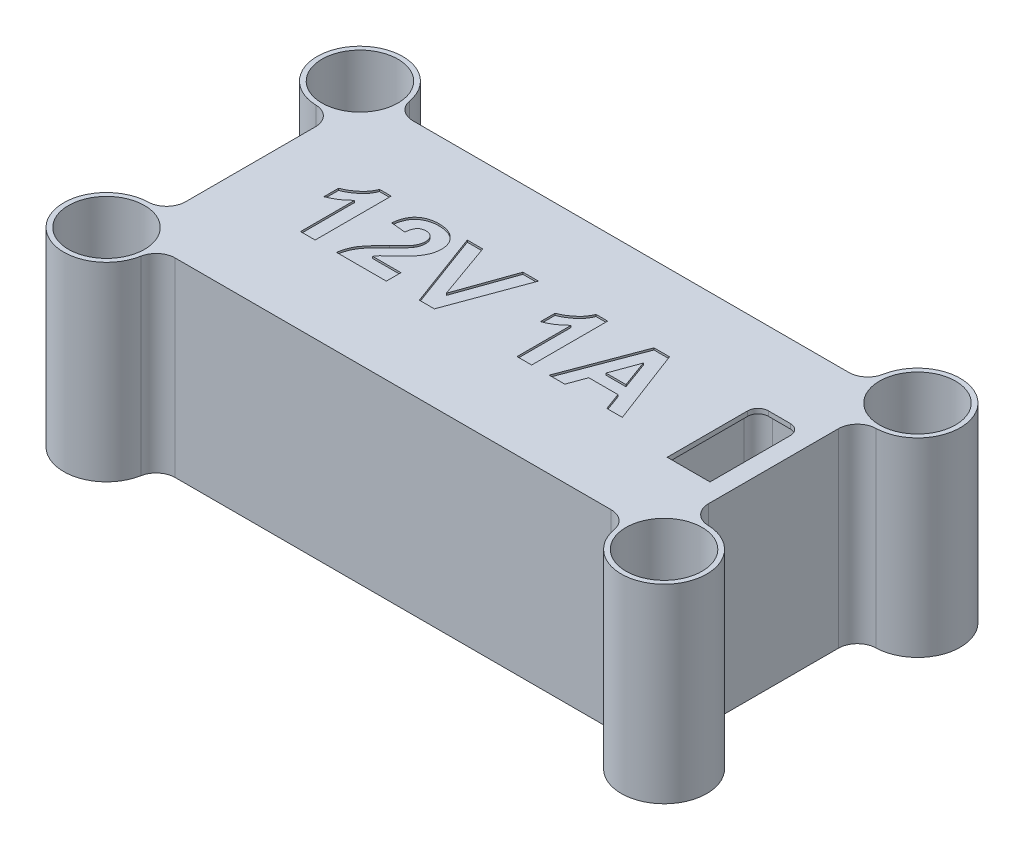
from build123d import *

# Parameters (mm, degrees)
SKETCH1_R           = 2
BOSS_EXTRUDE1_DEPTH = 20
SKETCH2_R           = 4
CUT_EXTRUDE1_DEPTH  = 18.5
CUT_EXTRUDE2_REACH  = 22.5
CUT_EXTRUDE2_START  = -0.5
SKETCH5_W           = 6.8
SKETCH5_H           = 4.325
CUT_EXTRUDE4_DEPTH  = 18.5
CUT_EXTRUDE6_REACH  = 2.5
SKETCH8_W           = 6.8
SKETCH8_H           = 13.35
CUT_EXTRUDE7_DEPTH  = 8.8
FILLET1_R           = 2
CUT_EXTRUDE8_DEPTH  = 0.2
SKETCH10_W          = 1.8
SKETCH10_H          = 1.5
BOSS_EXTRUDE2_DEPTH = 1
CHAMFER1_SIZE       = 0.5


with BuildPart() as part:
    # Sketch1 → Boss-Extrude1 (new body)
    with BuildSketch(Plane(origin=(0, 0, 0), x_dir=(1, 0, 0), z_dir=(0, 1, 0))):
        with BuildLine():
            Line((-24.820732955, -12.5), (24.820732955, -12.5))
            Line((24.820732955, -12.5), (24.820732955, -13.327605889))
            ThreePointArc((24.820732955, -13.327605889), (32.50271347, -16.509586404), (29.320732955, -8.827605889))
            Line((29.320732955, -8.827605889), (27.5, -8.827605889))
            Line((27.5, -8.827605889), (27.5, 8.827605889))
            Line((27.5, 8.827605889), (29.320732955, 8.827605889))
            ThreePointArc((29.320732955, 8.827605889), (32.50271347, 16.509586404), (24.820732955, 13.327605889))
            Line((24.820732955, 13.327605889), (24.820732955, 12.5))
            Line((24.820732955, 12.5), (-24.820732955, 12.5))
            Line((-24.820732955, 12.5), (-24.820732955, 13.327605889))
            ThreePointArc((-24.820732955, 13.327605889), (-32.50271347, 16.509586404), (-29.320732955, 8.827605889))
            Line((-29.320732955, 8.827605889), (-27.5, 8.827605889))
            Line((-27.5, 8.827605889), (-27.5, -8.827605889))
            Line((-27.5, -8.827605889), (-29.320732955, -8.827605889))
            ThreePointArc((-29.320732955, -8.827605889), (-32.50271347, -16.509586404), (-24.820732955, -13.327605889))
            Line((-24.820732955, -13.327605889), (-24.820732955, -12.5))
        make_face()
        with Locations((-29.320732955, -13.327605889)):
            Circle(SKETCH1_R, mode=Mode.SUBTRACT)
        with Locations((29.320732955, -13.327605889)):
            Circle(SKETCH1_R, mode=Mode.SUBTRACT)
        with Locations((-29.320732955, 13.327605889)):
            Circle(SKETCH1_R, mode=Mode.SUBTRACT)
        with Locations((29.320732955, 13.327605889)):
            Circle(SKETCH1_R, mode=Mode.SUBTRACT)
    extrude(amount=BOSS_EXTRUDE1_DEPTH)

    # Sketch2 → Cut-Extrude1 (cut)
    with BuildSketch(Plane(origin=(0, 20, 0), x_dir=(1, 0, 0), z_dir=(0, 1, 0))):
        with Locations((-29.320732955, 13.327605889)):
            Circle(SKETCH2_R)
        with Locations((29.320732955, 13.327605889)):
            Circle(SKETCH2_R)
        with Locations((29.320732955, -13.327605889)):
            Circle(SKETCH2_R)
        with Locations((-29.320732955, -13.327605889)):
            Circle(SKETCH2_R)
    extrude(amount=-CUT_EXTRUDE1_DEPTH, mode=Mode.SUBTRACT)

    # Sketch3 → Cut-Extrude2 (cut, up to next)
    with BuildSketch(Plane(origin=(0, 20, 0), x_dir=(1, 0, 0), z_dir=(0, 1, 0)).offset(CUT_EXTRUDE2_START), mode=Mode.PRIVATE) as cut_extrude2_sk1:
        with BuildLine():
            Line((22.2, 5.175), (24.5, 5.175))
            ThreePointArc((24.5, 5.175), (25.560660172, 4.735660172), (26, 3.675))
            Line((26, 3.675), (26, -5.175))
            Line((26, -5.175), (20.7, -5.175))
            Line((20.7, -5.175), (20.7, 3.675))
            ThreePointArc((20.7, 3.675), (21.139339828, 4.735660172), (22.2, 5.175))
        make_face()
    cut_extrude2_tool1 = extrude(cut_extrude2_sk1.sketch, amount=-CUT_EXTRUDE2_REACH, mode=Mode.PRIVATE) & part.part
    add(cut_extrude2_tool1.solids().sort_by_distance((23.35, 19.5, 0.086733))[0], mode=Mode.SUBTRACT)

    # Sketch5 → Cut-Extrude4 (cut)
    with BuildSketch(Plane.XZ):
        Polygon((-26, -11), (19.2, -11), (19.2, -6.675), (19.2, 6.675), (19.2, 11), (-26, 11), align=None)
        with Locations((22.6, 8.8375)):
            Rectangle(SKETCH5_W, SKETCH5_H)
        with Locations((22.6, -8.8375)):
            Rectangle(SKETCH5_W, SKETCH5_H)
    extrude(amount=-CUT_EXTRUDE4_DEPTH, mode=Mode.SUBTRACT)

    # Sketch7 → Cut-Extrude6 (cut, up to next)
    with BuildSketch(Plane.XZ.offset(-19.5), mode=Mode.PRIVATE) as cut_extrude6_sk1:
        with BuildLine():
            Line((25.6, -3.675), (25.6, 4.775))
            Line((25.6, 4.775), (21.1, 4.775))
            Line((21.1, 4.775), (21.1, -3.675))
            ThreePointArc((21.1, -3.675), (21.422182541, -4.452817459), (22.2, -4.775))
            Line((22.2, -4.775), (24.5, -4.775))
            ThreePointArc((24.5, -4.775), (25.277817459, -4.452817459), (25.6, -3.675))
        make_face()
    cut_extrude6_tool1 = extrude(cut_extrude6_sk1.sketch, amount=-CUT_EXTRUDE6_REACH, mode=Mode.PRIVATE) & part.part
    add(cut_extrude6_tool1.solids().sort_by_distance((23.35, 19.5, 0.055404))[0], mode=Mode.SUBTRACT)

    # Sketch8 → Cut-Extrude7 (cut)
    with BuildSketch(Plane.XZ):
        with Locations((22.6, 0)):
            Rectangle(SKETCH8_W, SKETCH8_H)
    extrude(amount=-CUT_EXTRUDE7_DEPTH, mode=Mode.SUBTRACT)

    # Fillet1
    fillet1_edges = [part.edges().sort_by_distance(p)[0] for p in [
        (-24.820732955, 10, 12.5),
        (27.5, 10, -8.827605889),
        (27.5, 10, 8.827605889),
        (-24.820732955, 10, -12.5),
        (24.820732955, 10, -12.5),
        (-27.5, 10, 8.827605889),
        (24.820732955, 10, 12.5),
        (-27.5, 10, -8.827605889),
    ]]
    fillet(fillet1_edges, radius=FILLET1_R)

    # Sketch9 → Cut-Extrude8 (cut)
    with BuildSketch(Plane(origin=(0, 20, 0), x_dir=(1, 0, 0), z_dir=(0, 1, 0))):
        with BuildLine():
            Line((-17.2, -3.503303036), (-18.738461538, -3.503303036))
            Line((-18.738461538, -3.503303036), (-18.738461538, 2.192209784))
            add(Edge.make_bspline(
                [(-18.738461538, 2.192209784), (-18.80819288, 2.121419465), (-18.946709583, 1.980799172), (-19.167942577, 1.784652614), (-19.397616155, 1.602184599), (-19.638003147, 1.43512824), (-19.88596108, 1.281103277), (-20.144023944, 1.141325029), (-20.410321211, 1.013859466), (-20.594796858, 0.942626015), (-20.687179487, 0.906953374)],
                knots=[0, 0, 0, 0, 0.00029803, 0.000592016, 0.000886347, 0.001177542, 0.001469724, 0.001761589, 0.002057651, 0.002354645, 0.002354645, 0.002354645, 0.002354645], degree=3))
            Line((-20.687179487, 0.906953374), (-20.687179487, 2.445414912))
            add(Edge.make_bspline(
                [(-20.687179487, 2.445414912), (-20.5847225, 2.483831886), (-20.370287998, 2.564235622), (-20.053854784, 2.735258446), (-19.723569975, 2.947001956), (-19.446111881, 3.154673304), (-19.22582156, 3.339309728), (-19.071855374, 3.487728442), (-18.929196849, 3.639716903), (-18.803208237, 3.800180743), (-18.690582276, 3.965875737), (-18.590790764, 4.136531192), (-18.502951295, 4.3126862), (-18.456967947, 4.435356639), (-18.433974359, 4.496696964)],
                knots=[0, 0, 0, 0, 0.000327943, 0.000686359, 0.001076233, 0.001504439, 0.001725023, 0.00193811, 0.002145634, 0.002349865, 0.002549441, 0.002746237, 0.002942614, 0.003139025, 0.003139025, 0.003139025, 0.003139025], degree=3))
            Line((-18.433974359, 4.496696964), (-17.2, 4.496696964))
            Line((-17.2, 4.496696964), (-17.2, -3.503303036))
        make_face()
        with BuildLine():
            Line((-9.712820513, -1.964841498), (-9.712820513, -3.503303036))
            Line((-9.712820513, -3.503303036), (-14.943589744, -3.503303036))
            add(Edge.make_bspline(
                [(-14.943589744, -3.503303036), (-14.925879571, -3.371819176), (-14.890469156, -3.108925181), (-14.780992812, -2.724903224), (-14.634879393, -2.350163406), (-14.47630103, -2.045216154), (-14.318577283, -1.79974411), (-14.175474519, -1.598602421), (-14.004758175, -1.384596297), (-13.808905531, -1.155998115), (-13.588998948, -0.912093283), (-13.343397782, -0.653788587), (-13.070930478, -0.382320603), (-12.879244876, -0.197980484), (-12.780128205, -0.102662011)],
                knots=[0, 0, 0, 0, 0.000397572, 0.00079492, 0.001194293, 0.001602869, 0.001823371, 0.00206928, 0.002343089, 0.002644324, 0.002972255, 0.00332819, 0.003713472, 0.004126007, 0.004126007, 0.004126007, 0.004126007], degree=3))
            add(Edge.make_bspline(
                [(-12.780128205, -0.102662011), (-12.701031968, -0.026312487), (-12.550456028, 0.119034519), (-12.336035598, 0.32716554), (-12.147537945, 0.518497109), (-11.981021844, 0.688071002), (-11.840334053, 0.840205002), (-11.723623953, 0.972509867), (-11.629413426, 1.085524384), (-11.578388922, 1.157220864), (-11.555769231, 1.189004656)],
                knots=[0, 0, 0, 0, 0.000329805, 0.000627852, 0.000896419, 0.001135545, 0.001340805, 0.001517944, 0.001664865, 0.001781863, 0.001781863, 0.001781863, 0.001781863], degree=3))
            add(Edge.make_bspline(
                [(-11.555769231, 1.189004656), (-11.509449624, 1.265946471), (-11.420104469, 1.414358318), (-11.322130095, 1.647738631), (-11.263322223, 1.881070735), (-11.255252192, 2.036981913), (-11.251282051, 2.113684143)],
                knots=[0, 0, 0, 0, 0.00026914, 0.00051914, 0.000756628, 0.0009866, 0.0009866, 0.0009866, 0.0009866], degree=3))
            add(Edge.make_bspline(
                [(-11.251282051, 2.113684143), (-11.254163384, 2.193503126), (-11.259614642, 2.344514417), (-11.305324378, 2.557619273), (-11.386383176, 2.740813085), (-11.497986225, 2.894658171), (-11.639108504, 3.015195208), (-11.804084552, 3.104260377), (-11.995329354, 3.153501808), (-12.129747483, 3.159978593), (-12.2, 3.16336363)],
                knots=[0, 0, 0, 0, 0.000239319, 0.000452773, 0.000649334, 0.000836203, 0.001018022, 0.001201563, 0.001393984, 0.001604658, 0.001604658, 0.001604658, 0.001604658], degree=3))
            add(Edge.make_bspline(
                [(-12.2, 3.16336363), (-12.269777897, 3.160202258), (-12.40457373, 3.154095169), (-12.596147854, 3.100744479), (-12.763739856, 3.008388822), (-12.883174829, 2.903140642), (-12.963858819, 2.800794432), (-13.018834075, 2.711606451), (-13.066218454, 2.610261554), (-13.108204967, 2.497900715), (-13.141369566, 2.373236722), (-13.168078274, 2.237219018), (-13.189601628, 2.089115633), (-13.196446435, 1.986084348), (-13.2, 1.9325944)],
                knots=[0, 0, 0, 0, 0.000209078, 0.000403893, 0.00059037, 0.00077882, 0.00087693, 0.000980553, 0.001092377, 0.001212045, 0.001339949, 0.001478864, 0.001627765, 0.001788533, 0.001788533, 0.001788533, 0.001788533], degree=3))
            Line((-13.2, 1.9325944), (-14.738461538, 2.083235425))
            add(Edge.make_bspline(
                [(-14.738461538, 2.083235425), (-14.726092546, 2.18710097), (-14.702111046, 2.388479667), (-14.64226481, 2.67772891), (-14.56647177, 2.944574393), (-14.471118617, 3.188520899), (-14.360146411, 3.411119692), (-14.227894646, 3.609030537), (-14.078984341, 3.784445728), (-13.913286801, 3.937271904), (-13.731855422, 4.067995245), (-13.541475744, 4.184685887), (-13.338427216, 4.280409308), (-13.12494541, 4.359299788), (-12.901126802, 4.42234843), (-12.665936199, 4.464035337), (-12.420825112, 4.493358067), (-12.253511261, 4.495567224), (-12.167948718, 4.496696964)],
                knots=[0, 0, 0, 0, 0.000313677, 0.00060817, 0.000885094, 0.001144897, 0.001392875, 0.001629778, 0.001857139, 0.002081693, 0.002304143, 0.002527038, 0.002750686, 0.002976329, 0.003209231, 0.003447173, 0.003692281, 0.003948817, 0.003948817, 0.003948817, 0.003948817], degree=3))
            add(Edge.make_bspline(
                [(-12.167948718, 4.496696964), (-12.074931179, 4.494909215), (-11.893767843, 4.49142735), (-11.629301534, 4.462674079), (-11.380854439, 4.412538586), (-11.146254458, 4.346127029), (-10.927910808, 4.257462745), (-10.724004039, 4.150271313), (-10.537743287, 4.0204846), (-10.366352083, 3.875180428), (-10.213142059, 3.715392952), (-10.078943942, 3.544952595), (-9.966513201, 3.363978101), (-9.872166544, 3.17467535), (-9.802114788, 2.973998186), (-9.751072032, 2.764721424), (-9.717228629, 2.545868744), (-9.714306136, 2.396397327), (-9.712820513, 2.320414912)],
                knots=[0, 0, 0, 0, 0.000279012, 0.000543411, 0.000796727, 0.001038651, 0.001273748, 0.001502443, 0.001728263, 0.001953364, 0.002175515, 0.002391266, 0.002602926, 0.002813638, 0.003024495, 0.003239047, 0.00345934, 0.003687107, 0.003687107, 0.003687107, 0.003687107], degree=3))
            add(Edge.make_bspline(
                [(-9.712820513, 2.320414912), (-9.714777801, 2.233211241), (-9.718660761, 2.060212539), (-9.755837218, 1.804468773), (-9.812635608, 1.554622427), (-9.896579155, 1.310062898), (-10.002984117, 1.064923771), (-10.140142665, 0.818654809), (-10.299394112, 0.563828977), (-10.424081719, 0.399072957), (-10.488461538, 0.314004656)],
                knots=[0, 0, 0, 0, 0.000261459, 0.000518694, 0.000773703, 0.00102912, 0.001293213, 0.001574334, 0.001873992, 0.002193883, 0.002193883, 0.002193883, 0.002193883], degree=3))
            add(Edge.make_bspline(
                [(-10.488461538, 0.314004656), (-10.512794284, 0.283357491), (-10.564909384, 0.217718368), (-10.653570864, 0.117070924), (-10.756321894, 0.007132187), (-10.871711161, -0.114155642), (-11.003550198, -0.24249743), (-11.147095429, -0.38326033), (-11.308663262, -0.529243853), (-11.476008385, -0.684089577), (-11.644080905, -0.834798742), (-11.798563782, -0.977939038), (-11.938885637, -1.104587456), (-12.05851142, -1.221735571), (-12.164477487, -1.321388108), (-12.252964472, -1.408655133), (-12.325628174, -1.481423983), (-12.42575408, -1.594852158), (-12.553152933, -1.748263812), (-12.642783234, -1.894852986), (-12.685576923, -1.964841498)],
                knots=[0, 0, 0, 0, 0.000117382, 0.000251404, 0.000402224, 0.000568837, 0.000753549, 0.000954152, 0.001171912, 0.001406703, 0.00163815, 0.001849117, 0.002038525, 0.002205137, 0.002351358, 0.00247488, 0.002578006, 0.002659721, 0.00292877, 0.003174596, 0.003174596, 0.003174596, 0.003174596], degree=3))
            Line((-12.685576923, -1.964841498), (-9.712820513, -1.964841498))
        make_face()
        Polygon((-6.241666667, -3.503303036), (-9.2, 4.496696964), (-7.575, 4.496696964), (-5.456410256, -1.452020985), (-3.345833333, 4.496696964), (-1.712820513, 4.496696964), (-4.659935897, -3.503303036), align=None)
        with BuildLine():
            Line((5.569230769, -3.503303036), (4.030769231, -3.503303036))
            Line((4.030769231, -3.503303036), (4.030769231, 2.192209784))
            add(Edge.make_bspline(
                [(4.030769231, 2.192209784), (3.961037889, 2.121419465), (3.822521187, 1.980799172), (3.601288192, 1.784652614), (3.371614614, 1.602184599), (3.131227623, 1.43512824), (2.883269689, 1.281103277), (2.625206825, 1.141325029), (2.358909558, 1.013859466), (2.174433911, 0.942626015), (2.082051282, 0.906953374)],
                knots=[0, 0, 0, 0, 0.00029803, 0.000592016, 0.000886347, 0.001177542, 0.001469724, 0.001761589, 0.002057651, 0.002354645, 0.002354645, 0.002354645, 0.002354645], degree=3))
            Line((2.082051282, 0.906953374), (2.082051282, 2.445414912))
            add(Edge.make_bspline(
                [(2.082051282, 2.445414912), (2.184508269, 2.483831886), (2.398942772, 2.564235622), (2.715375985, 2.735258446), (3.045660795, 2.947001956), (3.323118889, 3.154673304), (3.543409209, 3.339309728), (3.697375396, 3.487728442), (3.84003392, 3.639716903), (3.966022533, 3.800180743), (4.078648494, 3.965875737), (4.178440005, 4.136531192), (4.266279475, 4.3126862), (4.312262823, 4.435356639), (4.33525641, 4.496696964)],
                knots=[0, 0, 0, 0, 0.000327943, 0.000686359, 0.001076233, 0.001504439, 0.001725023, 0.00193811, 0.002145634, 0.002349865, 0.002549441, 0.002746237, 0.002942614, 0.003139025, 0.003139025, 0.003139025, 0.003139025], degree=3))
            Line((4.33525641, 4.496696964), (5.569230769, 4.496696964))
            Line((5.569230769, 4.496696964), (5.569230769, -3.503303036))
        make_face()
        Polygon((15.107692308, -3.503303036), (13.476282051, -3.503303036), (12.801602564, -1.65714919), (9.731089744, -1.65714919), (9.056410256, -3.503303036), (7.415384615, -3.503303036), (10.439423077, 4.496696964), (12.069230769, 4.496696964), align=None)
        Polygon((12.312820513, -0.323815857), (11.261538462, 2.547979015), (10.213461538, -0.323815857), align=None, mode=Mode.SUBTRACT)
    extrude(amount=-CUT_EXTRUDE8_DEPTH, mode=Mode.SUBTRACT)

    # Sketch10 → Boss-Extrude2 (add)
    with BuildSketch(Plane.XZ.offset(-8.8)):
        with Locations((20.1, 0)):
            Rectangle(SKETCH10_W, SKETCH10_H)
    extrude(amount=BOSS_EXTRUDE2_DEPTH)

    # Chamfer1
    chamfer1_edges = [part.edges().sort_by_distance(p)[0] for p in [
        (21, 7.8, 0),
    ]]
    chamfer(chamfer1_edges, length=CHAMFER1_SIZE)


solid = part.part
